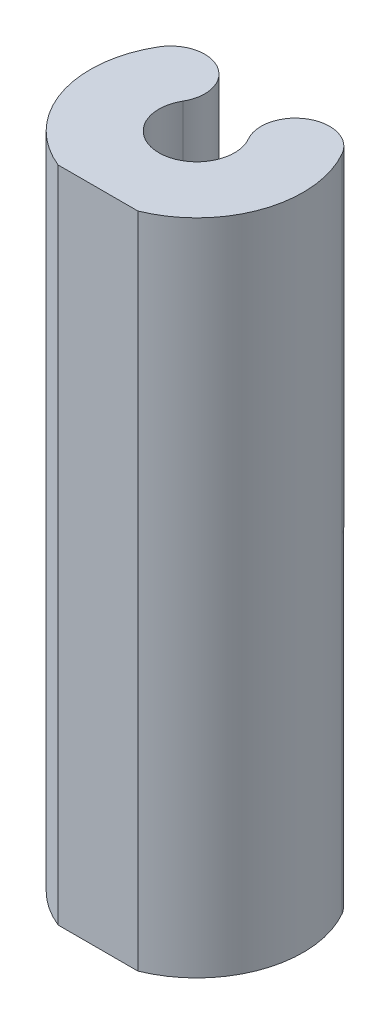
from build123d import *

# Parameters (mm, degrees)
BOSS_EXTRUDE1_DEPTH = 25.4
BOSS_EXTRUDE2_DEPTH = 25.4
CUT_EXTRUDE1_DEPTH  = 51.8


with BuildPart() as part:
    # Sketch1 → Boss-Extrude1 (new body)
    with BuildSketch(Plane(origin=(0, 0, 0), x_dir=(1, 0, 0), z_dir=(0, 1, 0))):
        with BuildLine():
            ThreePointArc((3.812810865, 2.209805629), (4.255786873, 1.144135352), (4.4069, 0))
            ThreePointArc((4.4069, 0), (-1.144135352, -4.255786873), (-3.812810865, 2.209805629))
            ThreePointArc((-3.812810865, 2.209805629), (-4.50575261, 4.813242153), (-7.109189135, 4.120300408))
            ThreePointArc((-7.109189135, 4.120300408), (-2.133301363, -7.935141518), (8.2169, 0))
            ThreePointArc((8.2169, 0), (7.935141518, 2.133301363), (7.109189135, 4.120300408))
            ThreePointArc((7.109189135, 4.120300408), (4.50575261, 4.813242153), (3.812810865, 2.209805629))
        make_face()
    extrude(amount=BOSS_EXTRUDE1_DEPTH)

    # Sketch2 → Boss-Extrude2 (add)
    with BuildSketch(Plane(origin=(0, 25.4, 0), x_dir=(1, 0, 0), z_dir=(0, 1, 0))):
        with BuildLine():
            ThreePointArc((-7.109189135, 4.120300408), (0, -8.2169), (7.109189135, 4.120300408))
            ThreePointArc((7.109189135, 4.120300408), (4.50575261, 4.813242153), (3.812810865, 2.209805629))
            ThreePointArc((3.812810865, 2.209805629), (0, -4.4069), (-3.812810865, 2.209805629))
            ThreePointArc((-3.812810865, 2.209805629), (-4.50575261, 4.813242153), (-7.109189135, 4.120300408))
        make_face()
        with BuildLine():
            ThreePointArc((2.52722334, 1.464712665), (2.820838561, 0.758360608), (2.921, 0))
            ThreePointArc((2.921, 0), (-0.758360608, -2.820838561), (-2.52722334, 1.464712665))
            ThreePointArc((-2.52722334, 1.464712665), (-3.490412365, 5.083489434), (-7.109189135, 4.120300408))
            ThreePointArc((-7.109189135, 4.120300408), (-4.50575261, 4.813242153), (-3.812810865, 2.209805629))
            ThreePointArc((-3.812810865, 2.209805629), (0, -4.4069), (3.812810865, 2.209805629))
            ThreePointArc((3.812810865, 2.209805629), (4.50575261, 4.813242153), (7.109189135, 4.120300408))
            ThreePointArc((7.109189135, 4.120300408), (3.490412365, 5.083489434), (2.52722334, 1.464712665))
        make_face()
    extrude(amount=BOSS_EXTRUDE2_DEPTH)

    # Sketch3 → Cut-Extrude1 (cut, through all)
    with BuildSketch(Plane(origin=(0, 50.8, 0), x_dir=(1, 0, 0), z_dir=(0, 1, 0))):
        with BuildLine():
            Line((3.074580558, -7.62), (-3.074580558, -7.62))
            ThreePointArc((-3.074580558, -7.62), (0, -8.2169), (3.074580558, -7.62))
        make_face()
    extrude(amount=-CUT_EXTRUDE1_DEPTH, mode=Mode.SUBTRACT)


solid = part.part
